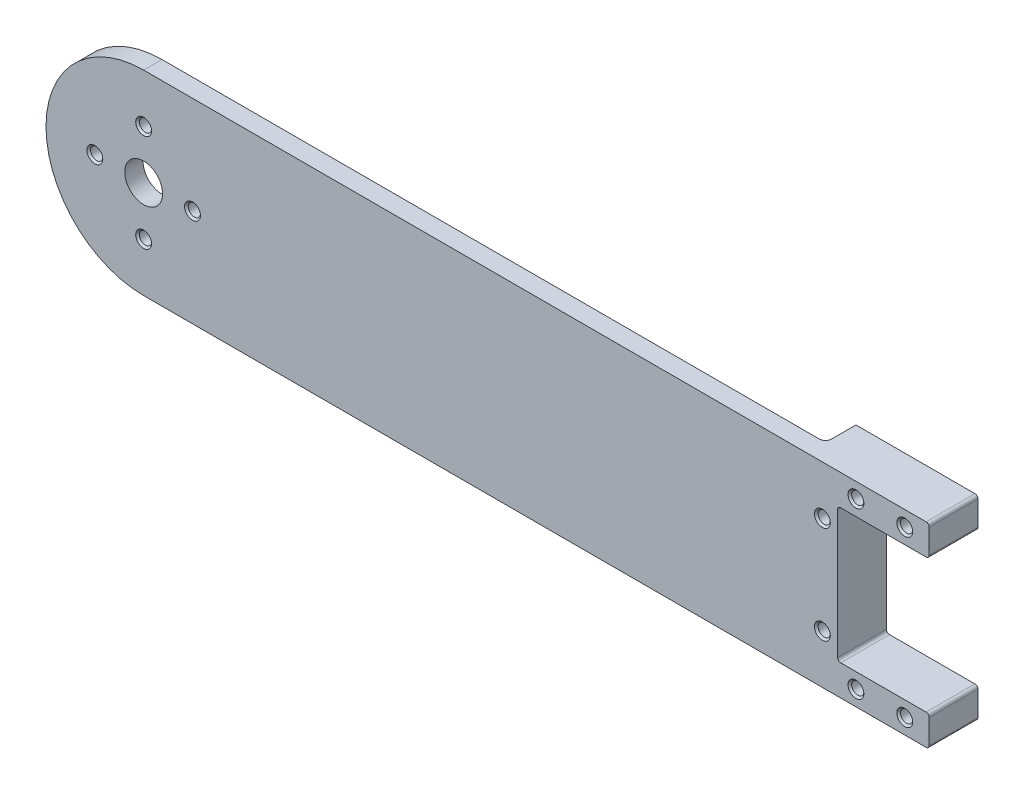
from build123d import *

# Parameters (mm, degrees)
Y_KSEKLIK_EKSTR_ZYON1_DEPTH                    = 3
IZIM2_R                                        = 3.1
KES_EKSTR_ZYON1_DEPTH                          = 79.70196948
M2_D_Z_BA_L_MAKINE_VIDAS_IN_HAV_A1_D           = 2
M2_D_Z_BA_L_MAKINE_VIDAS_IN_HAV_A1_CSINK_D     = 2.6
M2_D_Z_BA_L_MAKINE_VIDAS_IN_HAV_A1_CSINK_ANGLE = 90
IZIM26_W                                       = 22.3
IZIM26_H                                       = 22
KES_EKSTR_ZYON4_DEPTH                          = 79.70196948
Y_KSEKLIK_EKSTR_ZYON3_DEPTH                    = 8
M2_D_Z_BA_L_MAKINE_VIDAS_IN_HAV_A2_D           = 2
M2_D_Z_BA_L_MAKINE_VIDAS_IN_HAV_A2_CSINK_D     = 2.6
M2_D_Z_BA_L_MAKINE_VIDAS_IN_HAV_A2_CSINK_ANGLE = 90
RADYUS1_R                                      = 1
IZIM38_W                                       = 7.3
IZIM38_H                                       = 32
KES_EKSTR_ZYON5_DEPTH                          = 80.050616696
RADYUS2_R                                      = 0.5


with BuildPart() as part:
    # Çizim1 → Yükseklik-Ekstrüzyon1 (new body)
    with BuildSketch(Plane.XY):
        with BuildLine():
            ThreePointArc((-61, 16), (-77, 0), (-61, -16))
            Line((-61, -16), (75, -16))
            Line((75, -16), (75, 16))
            Line((75, 16), (-61, 16))
        make_face()
    extrude(amount=Y_KSEKLIK_EKSTR_ZYON1_DEPTH)

    # Çizim2 → Kes-Ekstrüzyon1 (cut, through all)
    with BuildSketch(Plane.XY.offset(3)):
        with Locations((-61, 0)):
            Circle(IZIM2_R)
    extrude(amount=-KES_EKSTR_ZYON1_DEPTH, mode=Mode.SUBTRACT)

    # M2 Düz Başlı Makine Vidası İçin Havşa1 (through all)
    with Locations(Plane(origin=(-61, 8, 3), x_dir=(1, 0, 0), z_dir=(0, 0, 1))):
        with Locations((0, 0), (8, -8), (0, -16), (-8, -8)):
            CounterSinkHole(M2_D_Z_BA_L_MAKINE_VIDAS_IN_HAV_A1_D / 2, M2_D_Z_BA_L_MAKINE_VIDAS_IN_HAV_A1_CSINK_D / 2, counter_sink_angle=M2_D_Z_BA_L_MAKINE_VIDAS_IN_HAV_A1_CSINK_ANGLE)

    # Çizim26 → Kes-Ekstrüzyon4 (cut, through all)
    with BuildSketch(Plane.XY.offset(3)):
        with Locations((63.85, 0)):
            Rectangle(IZIM26_W, IZIM26_H)
    extrude(amount=-KES_EKSTR_ZYON4_DEPTH, mode=Mode.SUBTRACT)

    # Çizim33 → Yükseklik-Ekstrüzyon3 (add)
    with BuildSketch(Plane.XY.offset(3)):
        Polygon((75, 11), (75, 16), (47.7, 16), (47.7, -16), (75, -16), (75, -11), (52.7, -11), (52.7, 11), align=None)
    extrude(amount=-Y_KSEKLIK_EKSTR_ZYON3_DEPTH)

    # M2 Düz Başlı Makine Vidası İçin Havşa2 (through all)
    with Locations(Plane(origin=(71.7, 13.5, 3), x_dir=(1, 0, 0), z_dir=(0, 0, 1))):
        with Locations((0, 0), (-8, 0), (-16, 0), (-21.5, -5.5), (-21.5, -21.5), (-16, -27), (-8, -27), (0, -27)):
            CounterSinkHole(M2_D_Z_BA_L_MAKINE_VIDAS_IN_HAV_A2_D / 2, M2_D_Z_BA_L_MAKINE_VIDAS_IN_HAV_A2_CSINK_D / 2, counter_sink_angle=M2_D_Z_BA_L_MAKINE_VIDAS_IN_HAV_A2_CSINK_ANGLE)

    # Radyus1
    radyus1_edges = [part.edges().sort_by_distance(p)[0] for p in [
        (47.7, 0, 0),
    ]]
    fillet(radyus1_edges, radius=RADYUS1_R)

    # Çizim38 → Kes-Ekstrüzyon5 (cut, through all)
    with BuildSketch(Plane.XY.offset(3)):
        with Locations((71.35, 0)):
            Rectangle(IZIM38_W, IZIM38_H)
    extrude(amount=-KES_EKSTR_ZYON5_DEPTH, mode=Mode.SUBTRACT)

    # Radyus2
    radyus2_edges = [part.edges().sort_by_distance(p)[0] for p in [
        (67.7, -11, -1),
        (67.7, -16, -1),
        (67.7, 11, -1),
        (67.7, 16, -1),
        (52.7, -11, -1),
        (52.7, 11, -1),
    ]]
    fillet(radyus2_edges, radius=RADYUS2_R)


solid = part.part
